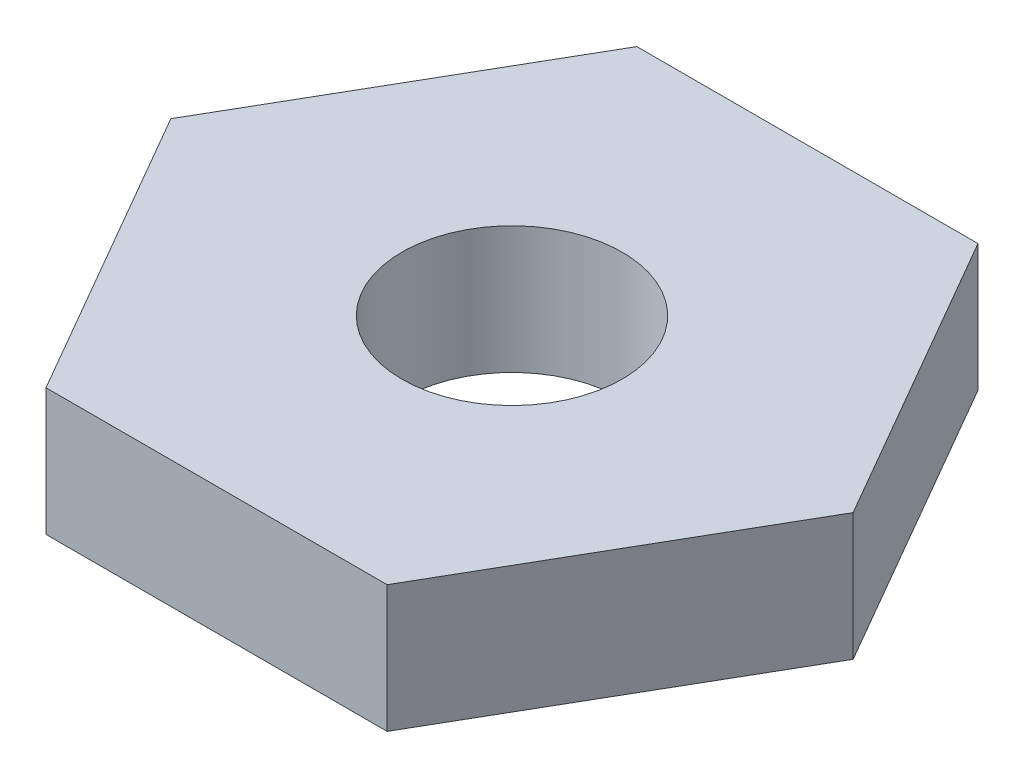
from build123d import *

# Parameters (mm, degrees)
SKETCH1_R           = 3.302
BOSS_EXTRUDE1_DEPTH = 3.81


with BuildPart() as part:
    # Sketch1 → Boss-Extrude1 (new body)
    with BuildSketch(Plane(origin=(0, 0, 0), x_dir=(1, 0, 0), z_dir=(0, 1, 0))):
        Polygon((10.229515579, 0), (5.11475779, 8.85902036), (-5.11475779, 8.85902036), (-10.229515579, 0), (-5.11475779, -8.85902036), (5.11475779, -8.85902036), align=None)
        Circle(SKETCH1_R, mode=Mode.SUBTRACT)
    extrude(amount=BOSS_EXTRUDE1_DEPTH)


solid = part.part
